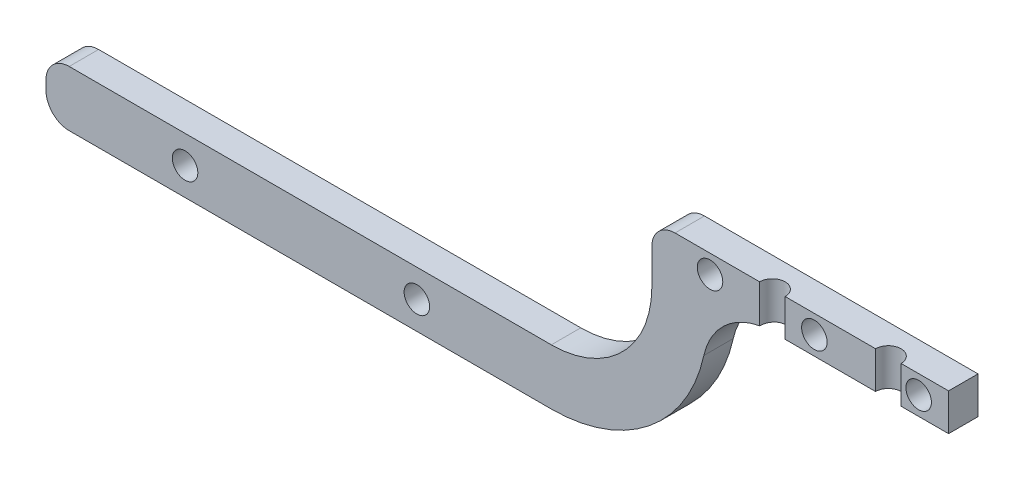
from build123d import *

# Parameters (mm, degrees)
BOSS_EXTRUDE1_DEPTH = 6.35
FILLET1_R           = 5
FILLET2_R           = 15
SKETCH4_R           = 2.75
CUT_EXTRUDE2_DEPTH  = 10
CUT_EXTRUDE3_REACH  = 48.24
SKETCH3_R           = 2.75


with BuildPart() as part:
    # Sketch1 → Boss-Extrude1 (new body)
    with BuildSketch(Plane.XY):
        with BuildLine():
            Line((0, 0), (-64, 0))
            Line((-64, 0), (-64, -12.552169744))
            ThreePointArc((-64, -12.552169744), (-70.352218413, -27.887781587), (-85.687830256, -34.24))
            Line((-85.687830256, -34.24), (-194.687830256, -34.24))
            Line((-194.687830256, -34.24), (-194.687830256, -46.24))
            Line((-194.687830256, -46.24), (-85.687830256, -46.24))
            ThreePointArc((-85.687830256, -46.24), (-61.866937038, -36.373062962), (-52, -12.552169744))
            Line((-52, -12.552169744), (-52, -8))
            Line((-52, -8), (0, -8))
            Line((0, -8), (0, 0))
        make_face()
    extrude(amount=BOSS_EXTRUDE1_DEPTH)

    # Fillet1
    fillet1_edges = [part.edges().sort_by_distance(p)[0] for p in [
        (-194.687830256, -46.24, 3.175),
        (-194.687830256, -34.24, 3.175),
        (-64, 0, 3.175),
    ]]
    fillet(fillet1_edges, radius=FILLET1_R)

    # Fillet2
    fillet2_edges = [part.edges().sort_by_distance(p)[0] for p in [
        (-52, -8, 3.175),
    ]]
    fillet(fillet2_edges, radius=FILLET2_R)

    # Sketch4 → Cut-Extrude2 (cut)
    with BuildSketch(Plane.XY.offset(6.35)):
        with Locations((-164.687830256, -40.24)):
            Circle(SKETCH4_R)
        with Locations((-114.687830256, -40.24)):
            Circle(SKETCH4_R)
        with Locations((-6.452530622, -4)):
            Circle(SKETCH4_R)
        with Locations((-28.952530622, -4)):
            Circle(SKETCH4_R)
        with Locations((-51.452530622, -4)):
            Circle(SKETCH4_R)
    extrude(amount=-CUT_EXTRUDE2_DEPTH, mode=Mode.SUBTRACT)

    # Sketch3 → Cut-Extrude3 (cut, up to next)
    with BuildSketch(Plane(origin=(0, 0, 0), x_dir=(1, 0, 0), z_dir=(0, 1, 0)), mode=Mode.PRIVATE) as cut_extrude3_sk1:
        with Locations((-13, -6.35)):
            Circle(SKETCH3_R)
    cut_extrude3_tool1 = extrude(cut_extrude3_sk1.sketch, amount=-CUT_EXTRUDE3_REACH, mode=Mode.PRIVATE) & part.part
    add(cut_extrude3_tool1.solids().sort_by_distance((-13, 0, 6.35))[0], mode=Mode.SUBTRACT)
    # Sketch3 → Cut-Extrude3 (cut, up to next)
    with BuildSketch(Plane(origin=(0, 0, 0), x_dir=(1, 0, 0), z_dir=(0, 1, 0)), mode=Mode.PRIVATE) as cut_extrude3_sk2:
        with Locations((-38, -6.35)):
            Circle(SKETCH3_R)
    cut_extrude3_tool2 = extrude(cut_extrude3_sk2.sketch, amount=-CUT_EXTRUDE3_REACH, mode=Mode.PRIVATE) & part.part
    add(cut_extrude3_tool2.solids().sort_by_distance((-38, 0, 6.35))[0], mode=Mode.SUBTRACT)


solid = part.part
